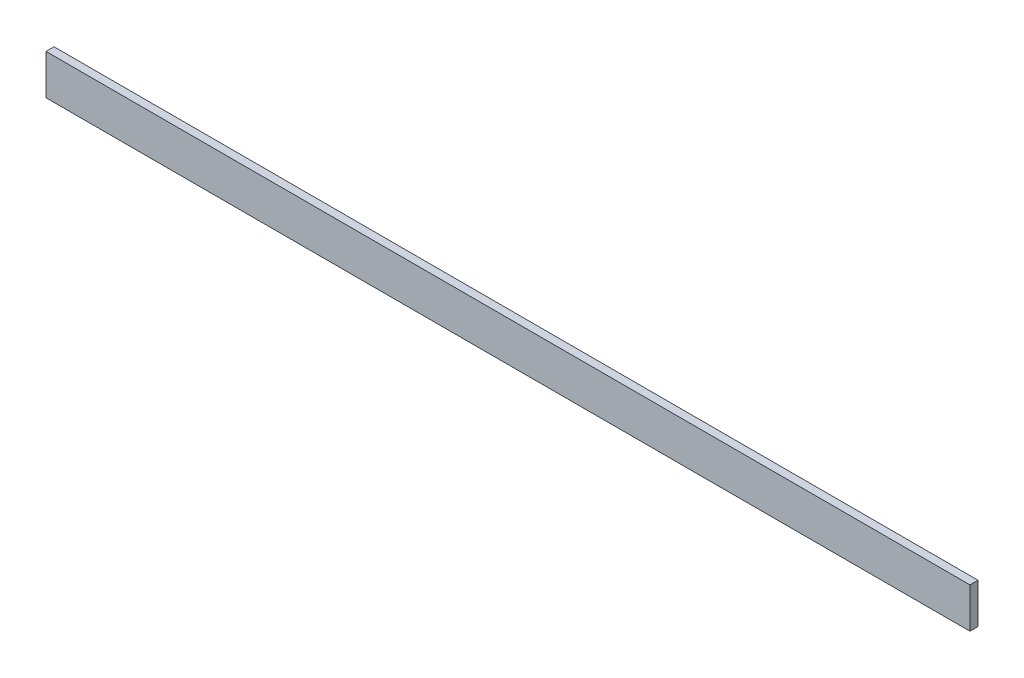
from build123d import *

# Parameters (mm, degrees)
ESBO_O1_W                = 2300
ESBO_O1_H                = 100
RESSALTO_EXTRUS_O1_DEPTH = 20


with BuildPart() as part:
    # Esboço1 → Ressalto-extrusão1 (new body)
    with BuildSketch(Plane.XY):
        with Locations((1150, 50)):
            Rectangle(ESBO_O1_W, ESBO_O1_H)
    extrude(amount=RESSALTO_EXTRUS_O1_DEPTH)


solid = part.part
